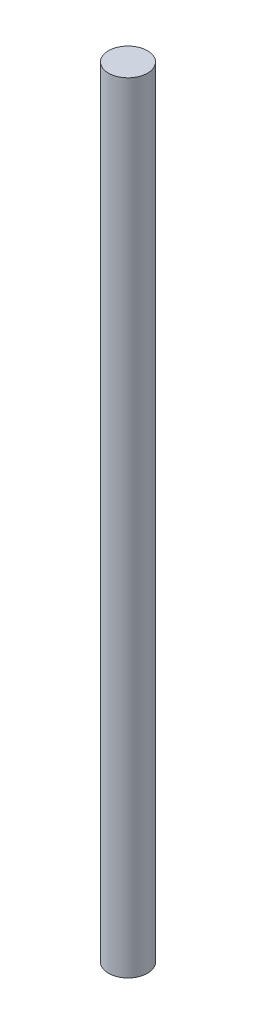
from build123d import *

# Parameters (mm, degrees)
SKETCH1_R           = 10
BOSS_EXTRUDE1_DEPTH = 400


with BuildPart() as part:
    # Sketch1 → Boss-Extrude1 (new body)
    with BuildSketch(Plane(origin=(0, 0, 0), x_dir=(1, 0, 0), z_dir=(0, 1, 0))):
        Circle(SKETCH1_R)
    extrude(amount=BOSS_EXTRUDE1_DEPTH)


solid = part.part
